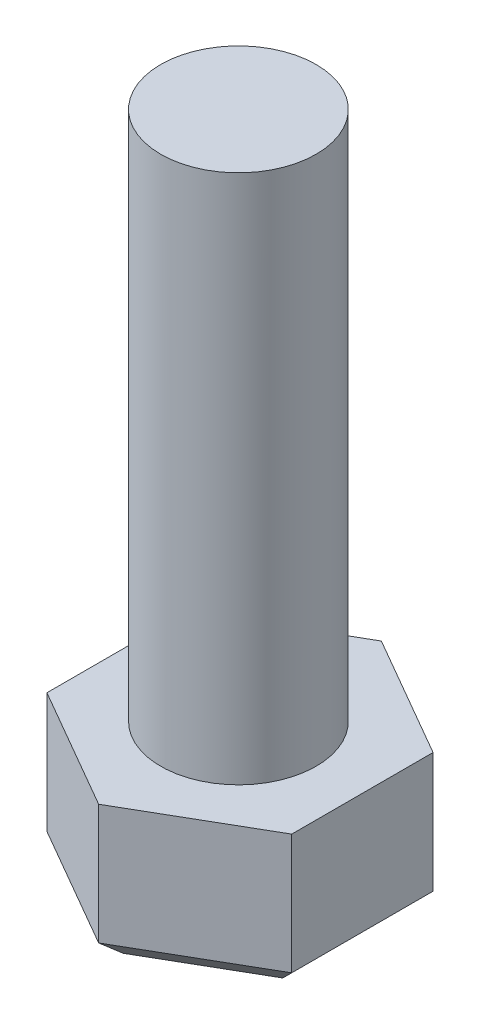
from build123d import *

# Parameters (mm, degrees)
SKETCH_1_R      = 11
EXTRUDE_4_DEPTH = 75
EXTRUDE_5_DEPTH = 20
CHAMFER_2_SIZE  = 3


with BuildPart() as part:
    # Эскиз1 → Бобышка-Вытянуть4 (new body)
    with BuildSketch(Plane(origin=(0, 0, 0), x_dir=(1, 0, 0), z_dir=(0, 1, 0))):
        Circle(SKETCH_1_R)
    extrude(amount=EXTRUDE_4_DEPTH)

    # Эскиз3 → Бобышка-Вытянуть5 (add)
    with BuildSketch(Plane.XZ):
        Polygon((0.259699185, 20.035631897), (-17.060808891, 10.035631897), (-17.060808891, -9.964368103), (0.259699185, -19.964368103), (17.58020726, -9.964368103), (17.58020726, 10.035631897), align=None)
    extrude(amount=EXTRUDE_5_DEPTH)

    # Фаска2
    chamfer_2_edges = [part.edges().sort_by_distance(p)[0] for p in [
        (8.919953222, -20, 15.035631897),
        (-8.400554853, -20, 15.035631897),
        (-17.060808891, -20, 0.035631897),
        (-8.400554853, -20, -14.964368103),
        (8.919953222, -20, -14.964368103),
        (17.58020726, -20, 0.035631897),
    ]]
    chamfer(chamfer_2_edges, length=CHAMFER_2_SIZE)


solid = part.part
